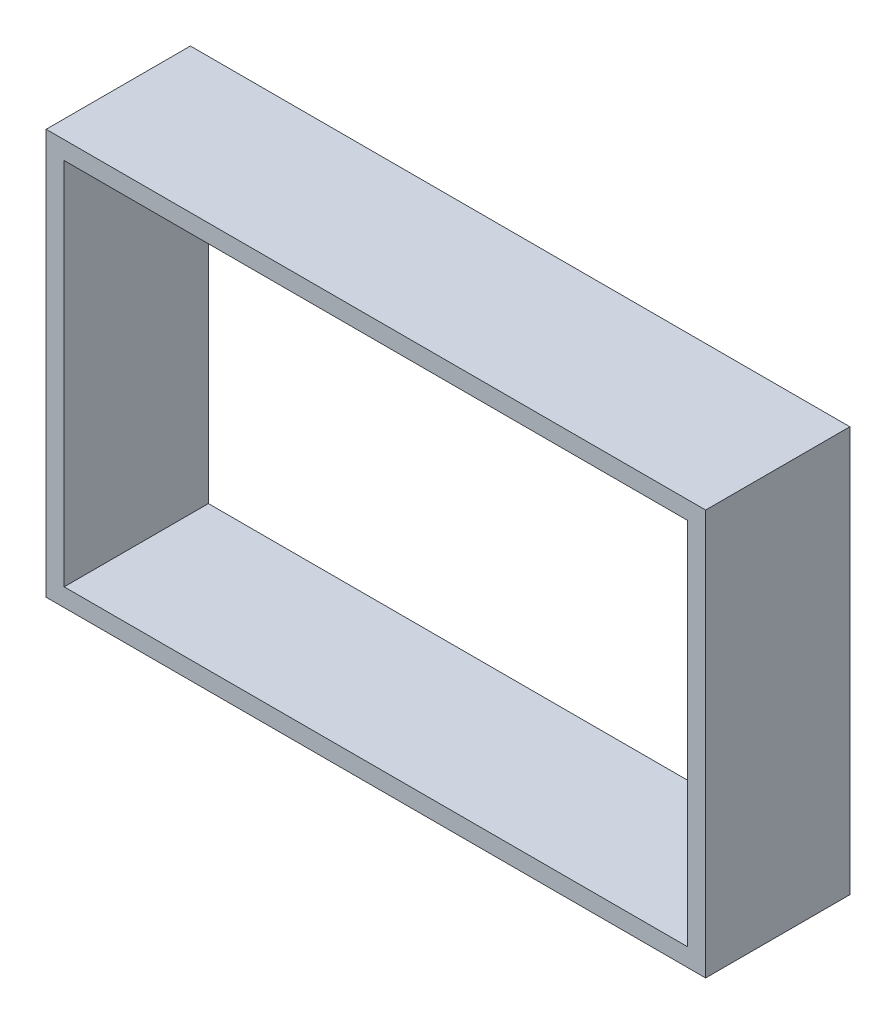
from build123d import *

# Parameters (mm, degrees)
SKETCH2_W           = 116.1415
SKETCH2_H           = 71.374
SKETCH2_W_2         = 109.7915
SKETCH2_H_2         = 65.024
BOSS_EXTRUDE1_DEPTH = 25.4


with BuildPart() as part:
    # Sketch2 → Boss-Extrude1 (new body)
    with BuildSketch(Plane.XY):
        Rectangle(SKETCH2_W, SKETCH2_H)
        Rectangle(SKETCH2_W_2, SKETCH2_H_2, mode=Mode.SUBTRACT)
    extrude(amount=-BOSS_EXTRUDE1_DEPTH)


solid = part.part
